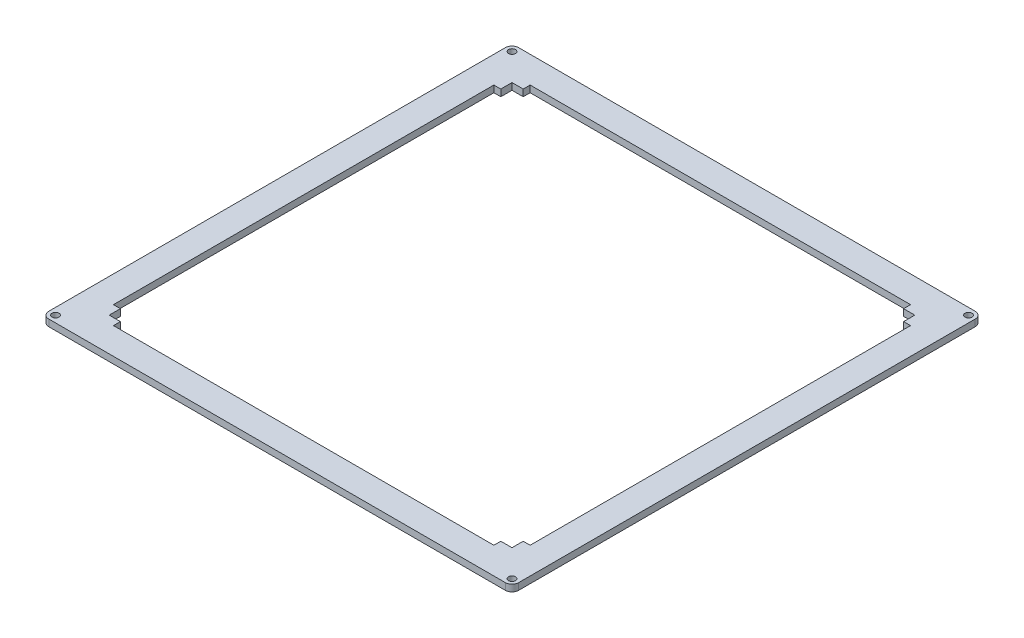
from build123d import *

# Parameters (mm, degrees)
SKETCH_3_R      = 1.55
EXTRUDE_1_DEPTH = 3


with BuildPart() as part:
    # 草图3 → 凸台-拉伸1 (new body)
    with BuildSketch(Plane(origin=(0, 0, 0), x_dir=(1, 0, 0), z_dir=(0, 1, 0))):
        with BuildLine():
            Line((0, 15), (0, 3))
            ThreePointArc((0, 3), (0.878679656, 0.878679656), (3, 0))
            Line((3, 0), (195, 0))
            Line((195, 0), (207, 0))
            ThreePointArc((207, 0), (209.121320344, 0.878679656), (210, 3))
            Line((210, 3), (210, 15))
            Line((210, 15), (210, 207))
            ThreePointArc((210, 207), (209.121320344, 209.121320344), (207, 210))
            Line((207, 210), (195, 210))
            Line((195, 210), (15, 210))
            Line((15, 210), (3, 210))
            ThreePointArc((3, 210), (0.878679656, 209.121320344), (0, 207))
            Line((0, 207), (0, 195))
            Line((0, 195), (0, 15))
        make_face()
        with Locations((3, 3)):
            Circle(SKETCH_3_R, mode=Mode.SUBTRACT)
        with Locations((207, 3)):
            Circle(SKETCH_3_R, mode=Mode.SUBTRACT)
        with Locations((3, 207)):
            Circle(SKETCH_3_R, mode=Mode.SUBTRACT)
        Polygon((192, 195), (195, 195), (195, 190), (198.1, 190), (198.1, 175), (198.1, 35), (198.1, 20), (195, 20), (195, 15), (192, 15), (190, 15), (190, 11.9), (175, 11.9), (35, 11.9), (20, 11.9), (20, 15), (18, 15), (15, 15), (15, 20), (11.9, 20), (11.9, 35), (11.9, 175), (11.9, 190), (15, 190), (15, 195), (18, 195), (20, 195), (20, 198.1), (35, 198.1), (175, 198.1), (190, 198.1), (190, 195), align=None, mode=Mode.SUBTRACT)
        with Locations((207, 207)):
            Circle(SKETCH_3_R, mode=Mode.SUBTRACT)
    extrude(amount=EXTRUDE_1_DEPTH)


solid = part.part
